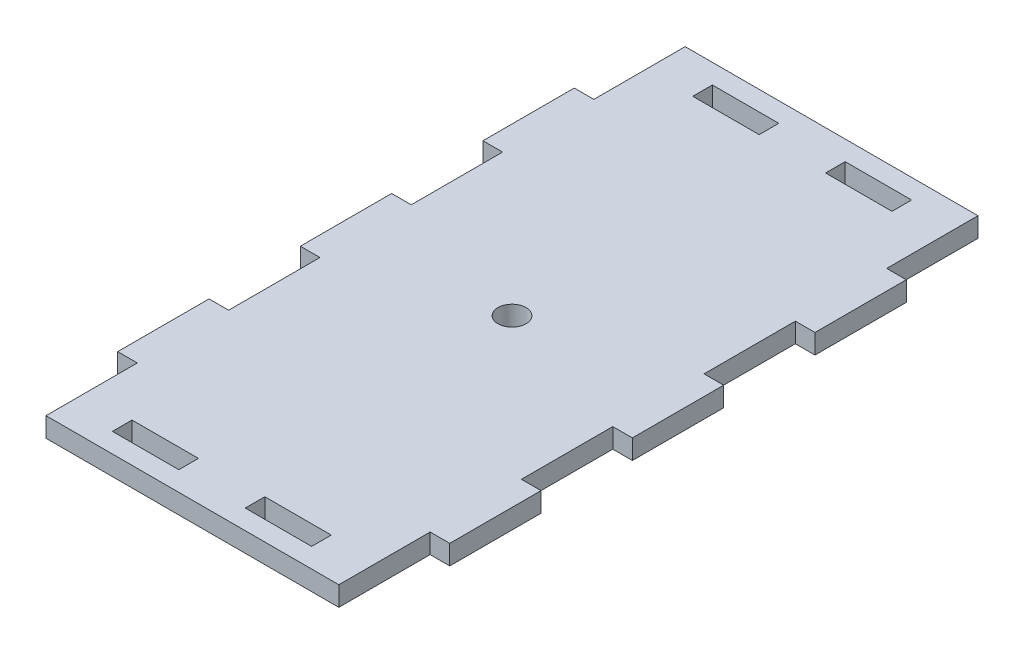
from build123d import *

# Parameters (mm, degrees)
SKETCH1_W             = 50.8
SKETCH1_H             = 97.79
BOSS_EXTRUDE1_DEPTH   = 3
SKETCH2_W             = 10.16
SKETCH2_H             = 3
SKETCH2_W_2           = 3
SKETCH2_H_2           = 13.97
CUT_EXTRUDE1_DEPTH    = 4
F_8_CLEARANCE_HOLE2_D = 4.3053


with BuildPart() as part:
    # Sketch1 → Boss-Extrude1 (new body)
    with BuildSketch(Plane(origin=(0, 0, 0), x_dir=(1, 0, 0), z_dir=(0, 1, 0))):
        with Locations((25.4, 48.895)):
            Rectangle(SKETCH1_W, SKETCH1_H)
    extrude(amount=BOSS_EXTRUDE1_DEPTH)

    # Sketch2 → Cut-Extrude1 (cut, through all)
    with BuildSketch(Plane(origin=(0, 3, 0), x_dir=(1, 0, 0), z_dir=(0, 1, 0))):
        with Locations((15.24, 93.29)):
            Rectangle(SKETCH2_W, SKETCH2_H)
        with Locations((35.56, 93.29)):
            Rectangle(SKETCH2_W, SKETCH2_H)
        with Locations((49.3, 90.805)):
            Rectangle(SKETCH2_W_2, SKETCH2_H_2)
        with Locations((49.3, 62.865)):
            Rectangle(SKETCH2_W_2, SKETCH2_H_2)
        with Locations((49.3, 34.925)):
            Rectangle(SKETCH2_W_2, SKETCH2_H_2)
        with Locations((49.3, 6.985)):
            Rectangle(SKETCH2_W_2, SKETCH2_H_2)
        with Locations((35.56, 4.5)):
            Rectangle(SKETCH2_W, SKETCH2_H)
        with Locations((15.24, 4.5)):
            Rectangle(SKETCH2_W, SKETCH2_H)
        with Locations((1.5, 6.985)):
            Rectangle(SKETCH2_W_2, SKETCH2_H_2)
        with Locations((1.5, 34.925)):
            Rectangle(SKETCH2_W_2, SKETCH2_H_2)
        with Locations((1.5, 62.865)):
            Rectangle(SKETCH2_W_2, SKETCH2_H_2)
        with Locations((1.5, 90.805)):
            Rectangle(SKETCH2_W_2, SKETCH2_H_2)
    extrude(amount=-CUT_EXTRUDE1_DEPTH, mode=Mode.SUBTRACT)

    # #8 Clearance Hole2 (through all)
    with Locations(Plane(origin=(0, 3, 0), x_dir=(1, 0, 0), z_dir=(0, 1, 0))):
        with Locations((25.4, 48.895)):
            Hole(F_8_CLEARANCE_HOLE2_D / 2)


solid = part.part
